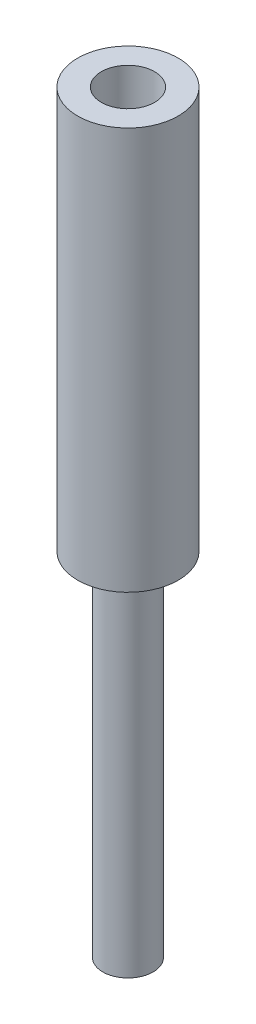
from build123d import *

# Parameters (mm, degrees)
SKETCH15_R           = 10
BOSS_EXTRUDE11_DEPTH = 80
SKETCH16_R           = 5.3
CUT_EXTRUDE1_DEPTH   = 70
SKETCH18_R           = 5
BOSS_EXTRUDE14_DEPTH = 70


with BuildPart() as part:
    # Sketch15 → Boss-Extrude11 (new body)
    with BuildSketch(Plane(origin=(0, 0, 0), x_dir=(1, 0, 0), z_dir=(0, 1, 0))):
        Circle(SKETCH15_R)
    extrude(amount=BOSS_EXTRUDE11_DEPTH)

    # Sketch16 → Cut-Extrude1 (cut)
    with BuildSketch(Plane(origin=(0, 80, 0), x_dir=(1, 0, 0), z_dir=(0, 1, 0))):
        Circle(SKETCH16_R)
    extrude(amount=-CUT_EXTRUDE1_DEPTH, mode=Mode.SUBTRACT)

    # Sketch18 → Boss-Extrude14 (add)
    with BuildSketch(Plane.XZ):
        Circle(SKETCH18_R)
    extrude(amount=BOSS_EXTRUDE14_DEPTH)


solid = part.part
